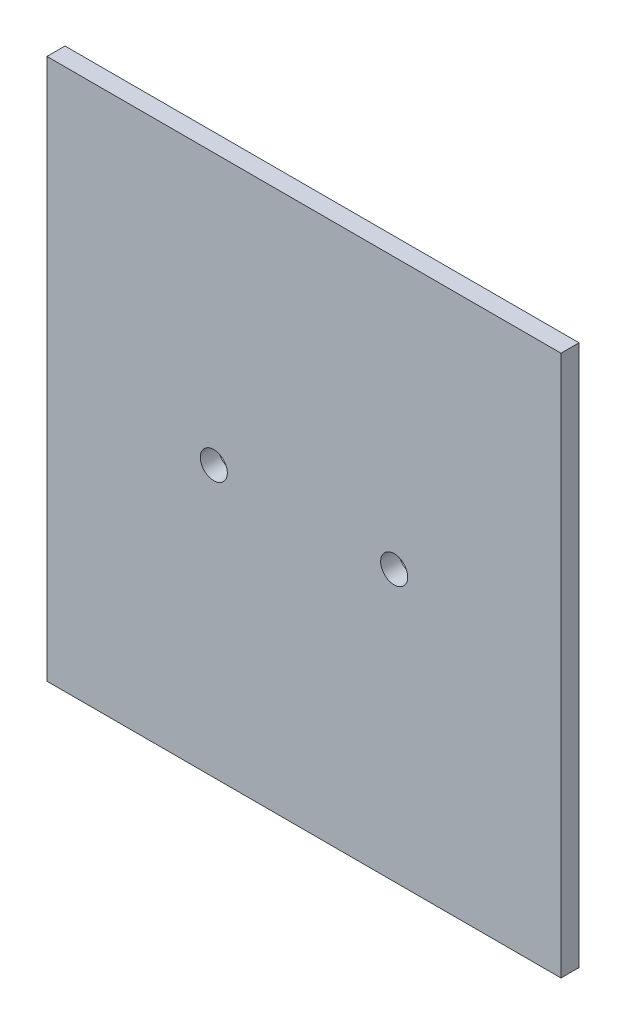
from build123d import *

# Parameters (mm, degrees)
SKETCH1_W           = 57
SKETCH1_H           = 60
SKETCH1_R           = 1.5
BOSS_EXTRUDE1_DEPTH = 2


with BuildPart() as part:
    # Sketch1 → Boss-Extrude1 (new body)
    with BuildSketch(Plane.XY):
        Rectangle(SKETCH1_W, SKETCH1_H)
        with Locations((-10, 0)):
            Circle(SKETCH1_R, mode=Mode.SUBTRACT)
        with Locations((10, 0)):
            Circle(SKETCH1_R, mode=Mode.SUBTRACT)
    extrude(amount=BOSS_EXTRUDE1_DEPTH)


solid = part.part
